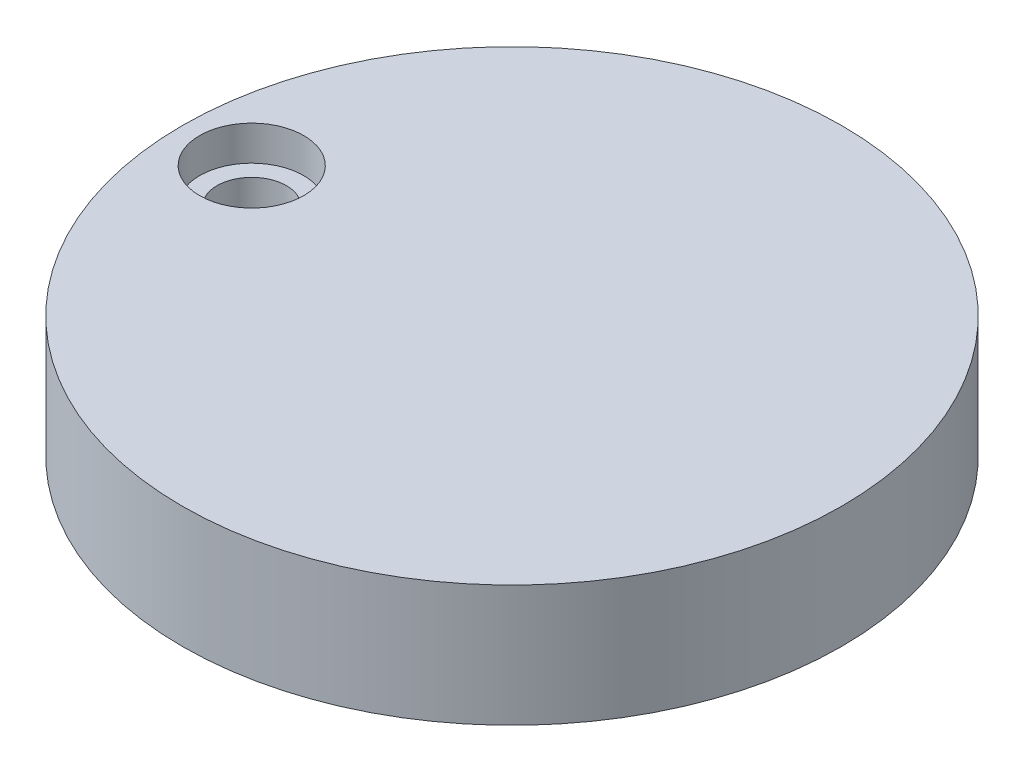
from build123d import *

# Parameters (mm, degrees)
CROQUIS2_R              = 19
SALIENTE_EXTRUIR1_DEPTH = 7
CROQUIS2_4_R            = 6
SALIENTE_EXTRUIR2_DEPTH = 8
CROQUIS2_5_R            = 2
CORTAR_EXTRUIR2_DEPTH   = 29.035691538
CROQUIS5_R              = 3
CORTAR_EXTRUIR3_DEPTH   = 2


with BuildPart() as part:
    # Croquis2 → Saliente-Extruir1 (new body)
    with BuildSketch(Plane(origin=(0, 0, 0), x_dir=(1, 0, 0), z_dir=(0, 1, 0))):
        Circle(CROQUIS2_R)
    extrude(amount=SALIENTE_EXTRUIR1_DEPTH)

    # Croquis2_4 → Saliente-Extruir2 (add)
    with BuildSketch(Plane(origin=(0, 0, 0), x_dir=(1, 0, 0), z_dir=(0, 1, 0))):
        Circle(CROQUIS2_4_R)
    extrude(amount=-SALIENTE_EXTRUIR2_DEPTH)

    # Croquis2_5 → Cortar-Extruir2 (cut, through all)
    with BuildSketch(Plane(origin=(0, 0, 0), x_dir=(1, 0, 0), z_dir=(0, 1, 0))):
        with Locations((-15, 0)):
            Circle(CROQUIS2_5_R)
    extrude(amount=CORTAR_EXTRUIR2_DEPTH, mode=Mode.SUBTRACT)

    # Croquis5 → Cortar-Extruir3 (cut)
    with BuildSketch(Plane(origin=(0, 7, 0), x_dir=(1, 0, 0), z_dir=(0, 1, 0))):
        with Locations((-15, 0)):
            Circle(CROQUIS5_R)
    extrude(amount=-CORTAR_EXTRUIR3_DEPTH, mode=Mode.SUBTRACT)


solid = part.part
